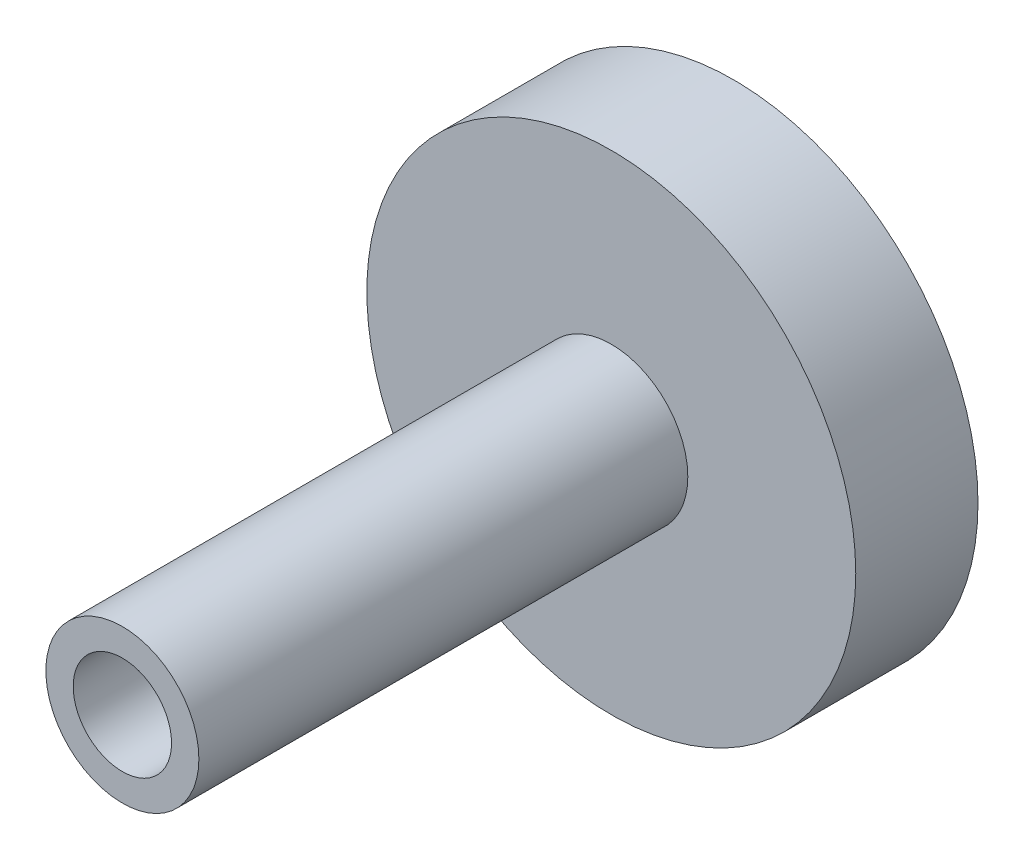
from build123d import *

# Parameters (mm, degrees)
SKETCH1_R           = 12.7
SKETCH1_R_2         = 2.555
BOSS_EXTRUDE1_DEPTH = 31.75
SKETCH2_R           = 12.7
SKETCH2_R_2         = 3.9751
CUT_EXTRUDE1_DEPTH  = 25.4


with BuildPart() as part:
    # Sketch1 → Boss-Extrude1 (new body)
    with BuildSketch(Plane.XY):
        Circle(SKETCH1_R)
        Circle(SKETCH1_R_2, mode=Mode.SUBTRACT)
    extrude(amount=BOSS_EXTRUDE1_DEPTH)

    # Sketch2 → Cut-Extrude1 (cut)
    with BuildSketch(Plane.XY.offset(31.75)):
        Circle(SKETCH2_R)
        Circle(SKETCH2_R_2, mode=Mode.SUBTRACT)
    extrude(amount=-CUT_EXTRUDE1_DEPTH, mode=Mode.SUBTRACT)


solid = part.part
